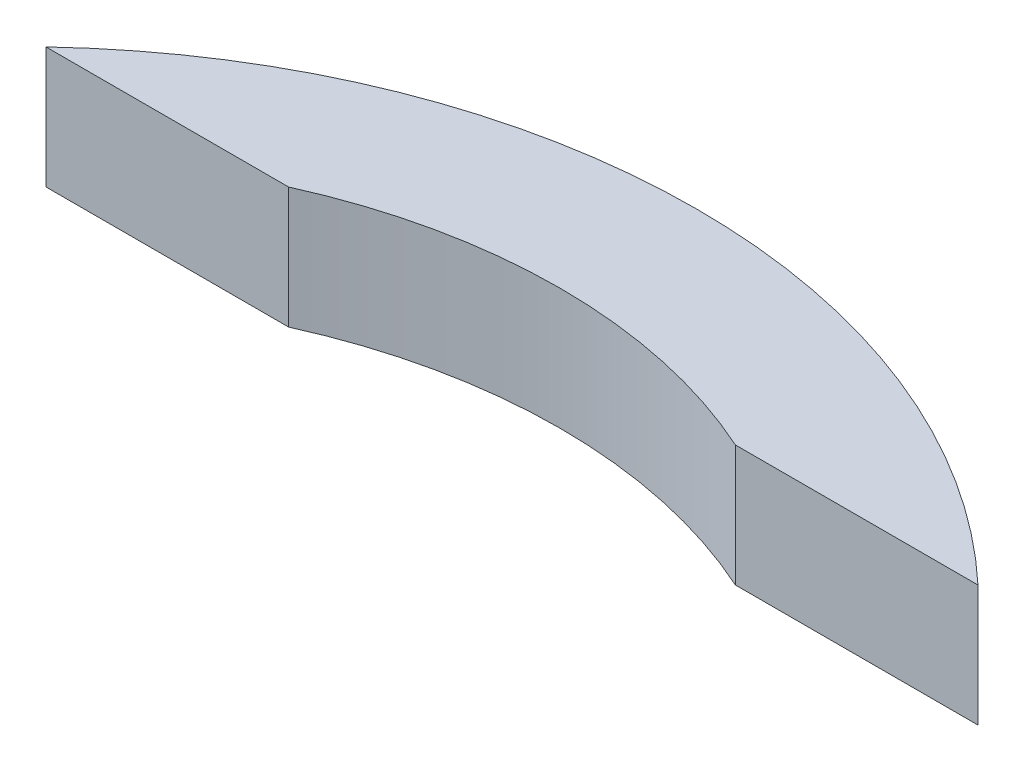
from build123d import *

# Parameters (mm, degrees)
SKETCH4_W          = 162
SKETCH4_H          = 81
SKETCH3_W          = 1325.375079923
SKETCH3_H          = 1989.116651683
CUT_EXTRUDE1_DEPTH = 341.499830867


with BuildPart() as part:
    # Sweep1: sweep along a curve in space
    with BuildLine() as sweep1_path:
        ThreePointArc((0, 0, 0), (426.052018636, 0, -108.716039096), (744.177847665, 0, 194.822190201))
    # Sketch4 → Sweep1 (sweep)
    with BuildSketch(Plane.XY):
        with Locations((81, 0)):
            Rectangle(SKETCH4_W, SKETCH4_H)
    sweep(path=sweep1_path.line)

    # Sketch3 → Cut-Extrude1 (cut, through all)
    with BuildSketch(Plane.XY):
        with Locations((416.341391421, -2.986328517)):
            Rectangle(SKETCH3_W, SKETCH3_H)
    extrude(amount=CUT_EXTRUDE1_DEPTH, mode=Mode.SUBTRACT)


solid = part.part
